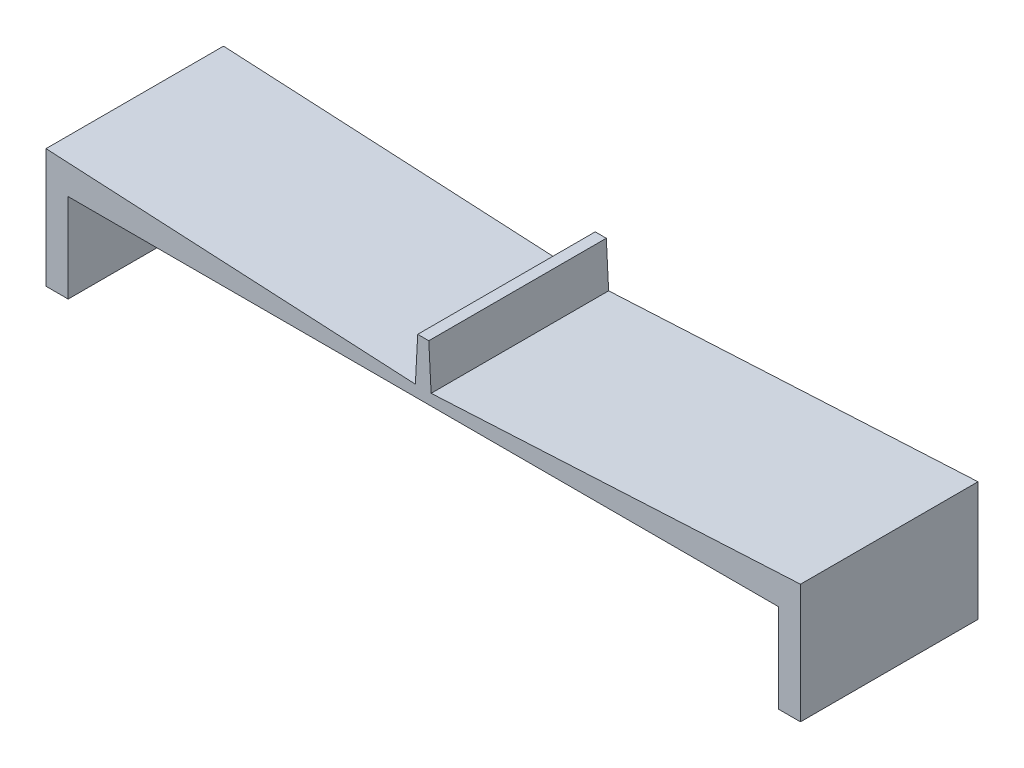
from build123d import *

# Parameters (mm, degrees)
SKETCH3_W           = 53.975
SKETCH3_H           = 1.5875
SKETCH3_W_2         = 3.175
SKETCH3_H_2         = 12.7
BOSS_EXTRUDE2_DEPTH = 25.4


with BuildPart() as part:
    # Sketch3 → Boss-Extrude2 (new body)
    with BuildSketch(Plane.XY):
        with Locations((26.9875, 0.79375)):
            Rectangle(SKETCH3_W, SKETCH3_H)
        with Locations((52.3875, -6.35)):
            Rectangle(SKETCH3_W_2, SKETCH3_H_2)
        Polygon((53.975, 4.357170459), (1.126539398, 1.5875), (53.975, 1.5875), align=None)
        Polygon((0, 7.9375), (0, 1.5875), (1.126539398, 1.5875), (0.79375, 7.9375), align=None)
    boss_extrude2 = extrude(amount=BOSS_EXTRUDE2_DEPTH)

    # Mirror1: Boss-Extrude2 across plane
    add(boss_extrude2.mirror(Plane(origin=(0, 0, 0), x_dir=(0, 0, 1), z_dir=(1, 0, 0))))


solid = part.part
